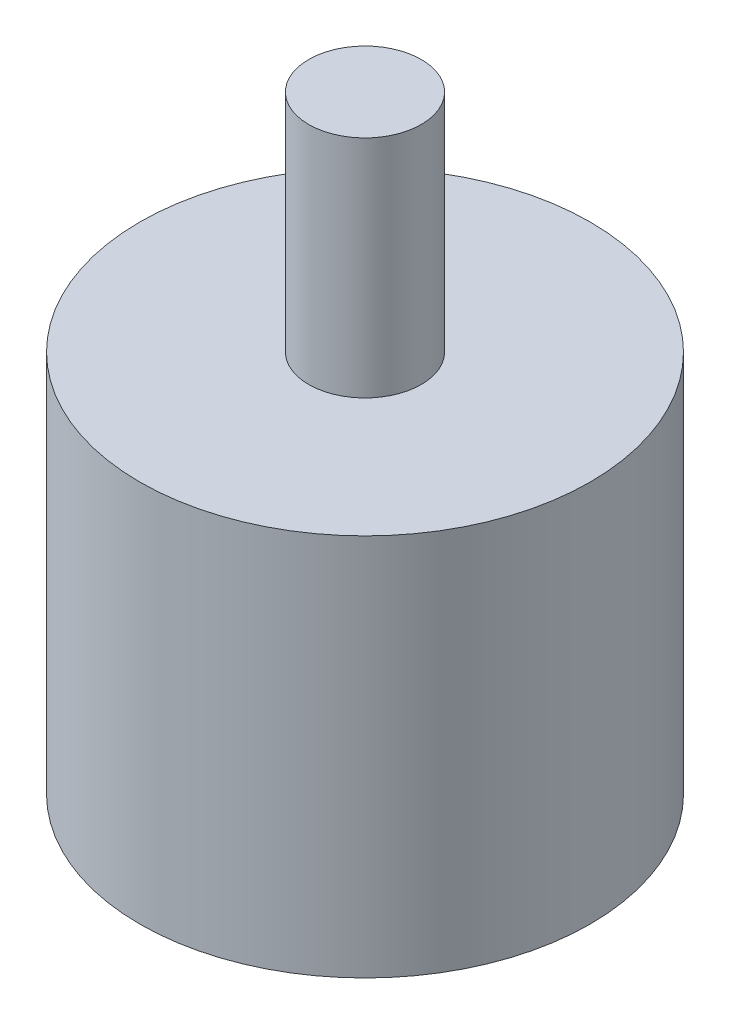
from build123d import *


with BuildPart() as part:
    # Skizze2 → Rotation1 (revolve)
    with BuildSketch(Plane(origin=(0, 0, 0), x_dir=(0, 0, -1), z_dir=(1, 0, 0))):
        Polygon((-190, 227.5), (-190, 208.5), (-187, 208.5), (-187, 200.5), (-180, 200.5), (-180, 217.5), (-187.5, 217.5), (-187.5, 227.5), align=None)
    revolve(axis=Axis((0, 227.5, 190), (0, -1, 0)))


solid = part.part
